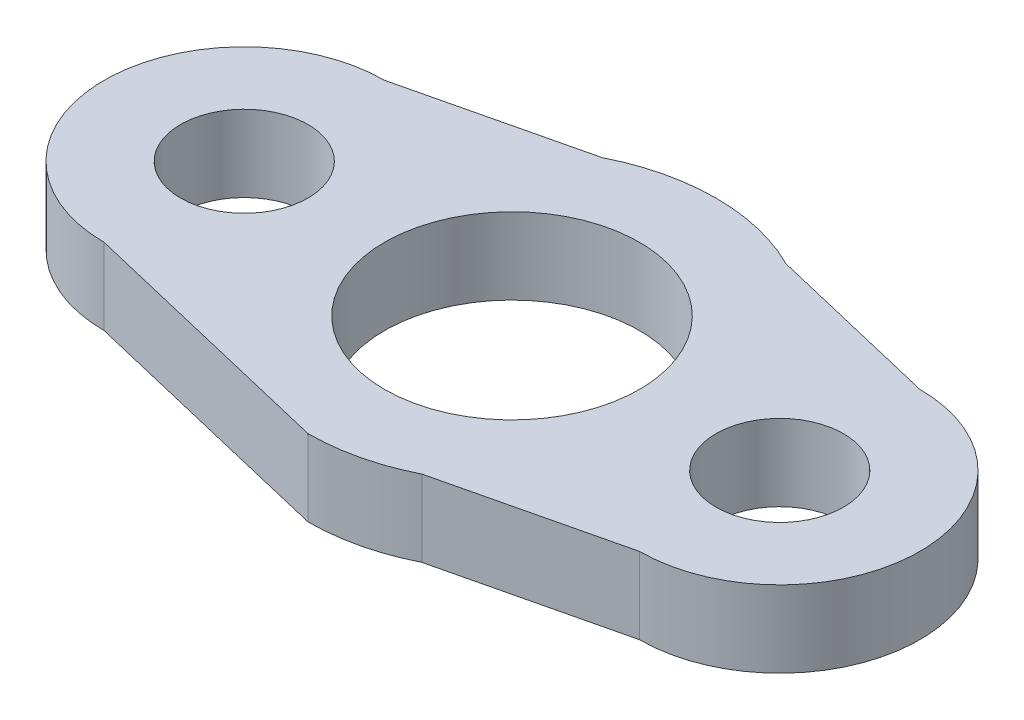
from build123d import *

# Parameters (mm, degrees)
ESQUISSE1_R        = 2.5
ESQUISSE1_R_2      = 5
BOSS_EXTRU_2_DEPTH = 3


with BuildPart() as part:
    # Esquisse1 → Boss.-Extru.2 (new body)
    with BuildSketch(Plane(origin=(0, 0, 0), x_dir=(1, 0, 0), z_dir=(0, 1, 0))):
        with BuildLine():
            ThreePointArc((0, -8), (1.852964218, -7.782449717), (3.605150215, -7.141630901))
            Line((3.605150215, -7.141630901), (10.5, -5.5))
            ThreePointArc((10.5, -5.5), (16, 0), (10.5, 5.5))
            Line((10.5, 5.5), (3.605150215, 7.141630901))
            ThreePointArc((3.605150215, 7.141630901), (0, 8), (-3.605150215, 7.141630901))
            Line((-3.605150215, 7.141630901), (-10.5, 5.5))
            ThreePointArc((-10.5, 5.5), (-16, 0), (-10.5, -5.5))
            Line((-10.5, -5.5), (0, -8))
        make_face()
        with Locations((-10.5, 0)):
            Circle(ESQUISSE1_R, mode=Mode.SUBTRACT)
        Circle(ESQUISSE1_R_2, mode=Mode.SUBTRACT)
        with Locations((10.5, 0)):
            Circle(ESQUISSE1_R, mode=Mode.SUBTRACT)
    extrude(amount=BOSS_EXTRU_2_DEPTH)


solid = part.part
